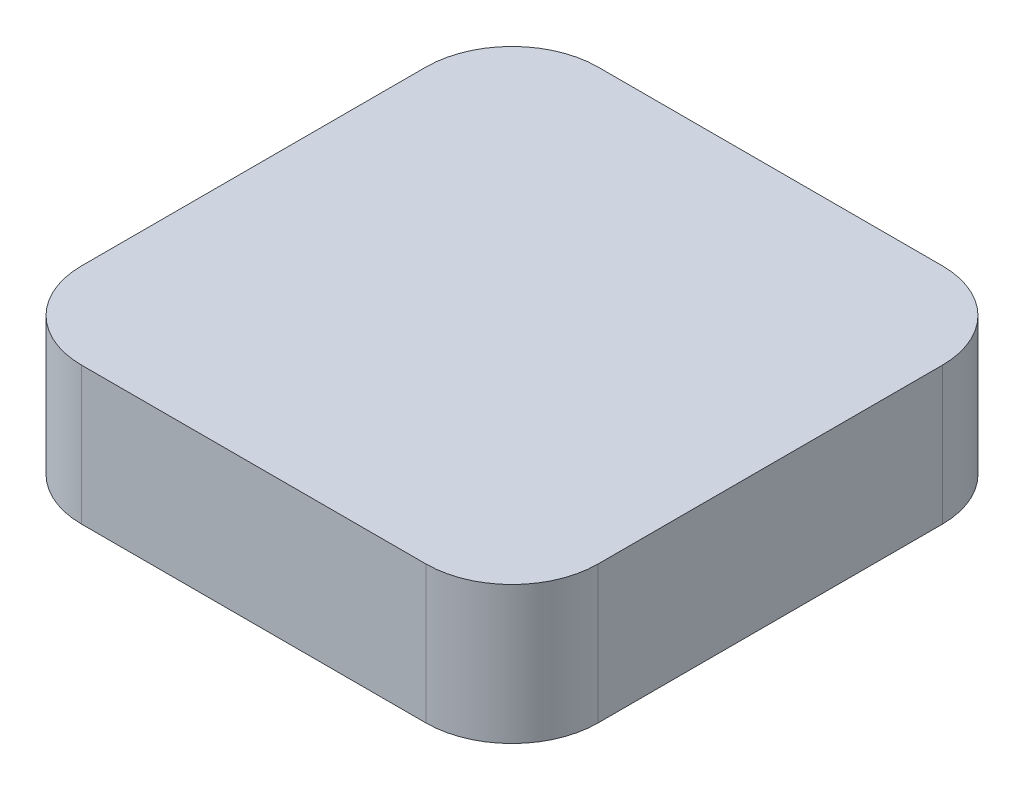
from build123d import *

# Parameters (mm, degrees)
BOSS_EXTRUDE1_DEPTH = 4


with BuildPart() as part:
    # Sketch1 → Boss-Extrude1 (new body)
    with BuildSketch(Plane(origin=(0, 0, 0), x_dir=(1, 0, 0), z_dir=(0, 1, 0))):
        with BuildLine():
            Line((-5, 7.5), (5, 7.5))
            ThreePointArc((5, 7.5), (6.767766953, 6.767766953), (7.5, 5))
            Line((7.5, 5), (7.5, -5))
            ThreePointArc((7.5, -5), (6.767766953, -6.767766953), (5, -7.5))
            Line((5, -7.5), (-5, -7.5))
            ThreePointArc((-5, -7.5), (-6.767766953, -6.767766953), (-7.5, -5))
            Line((-7.5, -5), (-7.5, 5))
            ThreePointArc((-7.5, 5), (-6.767766953, 6.767766953), (-5, 7.5))
        make_face()
    extrude(amount=BOSS_EXTRUDE1_DEPTH)


solid = part.part
